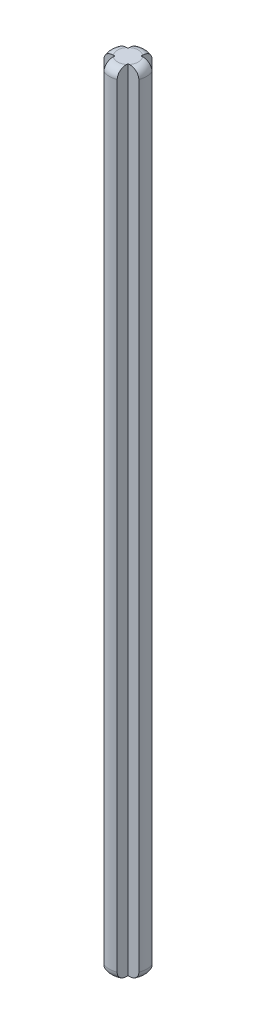
from build123d import *

# Parameters (mm, degrees)
BOSS_EXTRUDE1_DEPTH = 95.2
FILLET1_R           = 1
FILLET2_R           = 1
FILLET3_R           = 1
FILLET4_R           = 1
FILLET20_R          = 1
FILLET21_R          = 1
FILLET22_R          = 1
FILLET23_R          = 1


with BuildPart() as part:
    # Sketch1 → Boss-Extrude1 (new body)
    with BuildSketch(Plane(origin=(0, 0, 0), x_dir=(1, 0, 0), z_dir=(0, 1, 0))):
        with BuildLine():
            Line((-0.8, -0.8), (-0.8, -2.102974084))
            ThreePointArc((-0.8, -2.102974084), (0, -2.25), (0.8, -2.102974084))
            Line((0.8, -2.102974084), (0.8, -0.8))
            Line((0.8, -0.8), (2.102974084, -0.8))
            ThreePointArc((2.102974084, -0.8), (2.25, 0), (2.102974084, 0.8))
            Line((2.102974084, 0.8), (0.8, 0.8))
            Line((0.8, 0.8), (0.8, 2.102974084))
            ThreePointArc((0.8, 2.102974084), (0, 2.25), (-0.8, 2.102974084))
            Line((-0.8, 2.102974084), (-0.8, 0.8))
            Line((-0.8, 0.8), (-2.102974084, 0.8))
            ThreePointArc((-2.102974084, 0.8), (-2.25, 0), (-2.102974084, -0.8))
            Line((-2.102974084, -0.8), (-0.8, -0.8))
        make_face()
    extrude(amount=BOSS_EXTRUDE1_DEPTH)

    # Fillet1
    fillet1_edges = [part.edges().sort_by_distance(p)[0] for p in [
        (-2.25, 0, 0),
    ]]
    fillet(fillet1_edges, radius=FILLET1_R)

    # Fillet2
    fillet2_edges = [part.edges().sort_by_distance(p)[0] for p in [
        (0, 0, 2.25),
    ]]
    fillet(fillet2_edges, radius=FILLET2_R)

    # Fillet3
    fillet3_edges = [part.edges().sort_by_distance(p)[0] for p in [
        (2.25, 0, 0),
    ]]
    fillet(fillet3_edges, radius=FILLET3_R)

    # Fillet4
    fillet4_edges = [part.edges().sort_by_distance(p)[0] for p in [
        (0, 0, -2.25),
    ]]
    fillet(fillet4_edges, radius=FILLET4_R)

    # Fillet20
    fillet20_edges = [part.edges().sort_by_distance(p)[0] for p in [
        (2.25, 95.2, 0),
    ]]
    fillet(fillet20_edges, radius=FILLET20_R)

    # Fillet21
    fillet21_edges = [part.edges().sort_by_distance(p)[0] for p in [
        (0, 95.2, 2.25),
    ]]
    fillet(fillet21_edges, radius=FILLET21_R)

    # Fillet22
    fillet22_edges = [part.edges().sort_by_distance(p)[0] for p in [
        (-2.25, 95.2, 0),
    ]]
    fillet(fillet22_edges, radius=FILLET22_R)

    # Fillet23
    fillet23_edges = [part.edges().sort_by_distance(p)[0] for p in [
        (0, 95.2, -2.25),
    ]]
    fillet(fillet23_edges, radius=FILLET23_R)


solid = part.part
